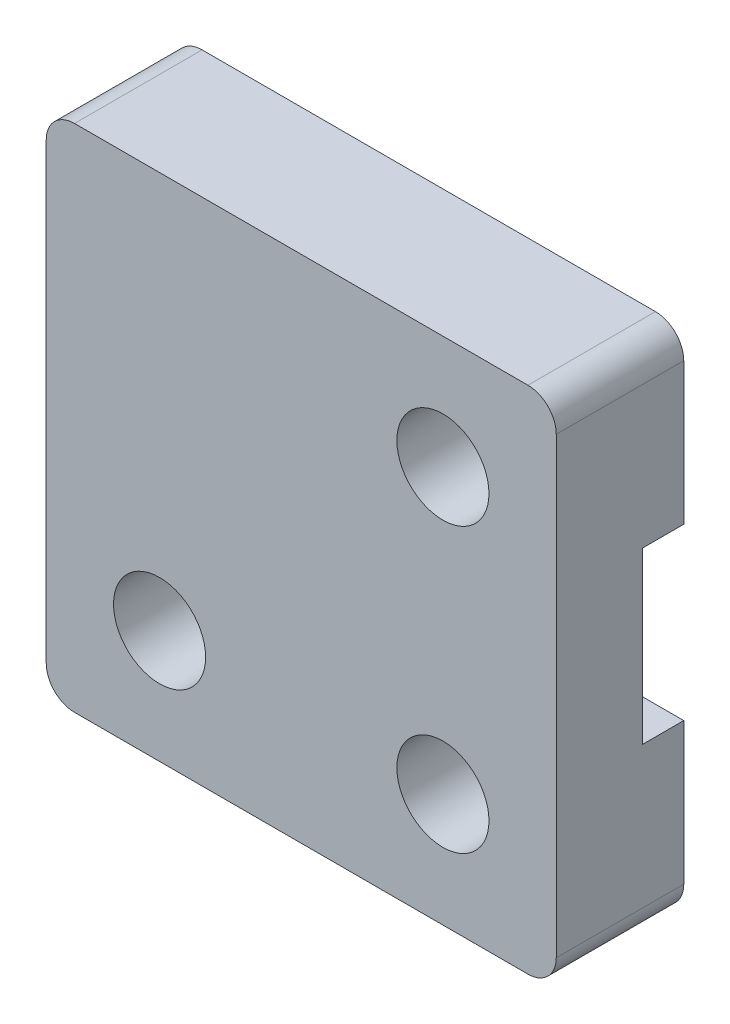
from build123d import *

# Parameters (mm, degrees)
SKETCH1_W           = 18
SKETCH1_H           = 18
SKETCH1_R           = 1.625
BOSS_EXTRUDE1_DEPTH = 4
SKETCH2_W           = 1
SKETCH2_H           = 6
CUT_EXTRUDE1_DEPTH  = 0.95
SKETCH3_R           = 1.625
BOSS_EXTRUDE2_DEPTH = 0.5
FILLET1_R           = 1


with BuildPart() as part:
    # Sketch1 → Boss-Extrude1 (new body)
    with BuildSketch(Plane.XY):
        with Locations((9, 9)):
            Rectangle(SKETCH1_W, SKETCH1_H)
        with Locations((4, 4)):
            Circle(SKETCH1_R, mode=Mode.SUBTRACT)
        with Locations((14, 4)):
            Circle(SKETCH1_R, mode=Mode.SUBTRACT)
        with Locations((14, 14)):
            Circle(SKETCH1_R, mode=Mode.SUBTRACT)
    extrude(amount=BOSS_EXTRUDE1_DEPTH)

    # Sketch2 → Cut-Extrude1 (cut)
    with BuildSketch(Plane(origin=(0, 0, 0), x_dir=(-1, 0, 0), z_dir=(0, 0, -1))):
        with Locations((-17.5, 9)):
            Rectangle(SKETCH2_W, SKETCH2_H)
        with Locations((-15.5, 9)):
            Rectangle(SKETCH2_W, SKETCH2_H)
        with Locations((-13.5, 9)):
            Rectangle(SKETCH2_W, SKETCH2_H)
        with Locations((-11.5, 9)):
            Rectangle(SKETCH2_W, SKETCH2_H)
        with Locations((-9.5, 9)):
            Rectangle(SKETCH2_W, SKETCH2_H)
        with Locations((-7.5, 9)):
            Rectangle(SKETCH2_W, SKETCH2_H)
        with Locations((-5.5, 9)):
            Rectangle(SKETCH2_W, SKETCH2_H)
        with Locations((-3.5, 9)):
            Rectangle(SKETCH2_W, SKETCH2_H)
        with Locations((-1.5, 9)):
            Rectangle(SKETCH2_W, SKETCH2_H)
    extrude(amount=-CUT_EXTRUDE1_DEPTH, mode=Mode.SUBTRACT)

    # Sketch3 → Boss-Extrude2 (add)
    with BuildSketch(Plane(origin=(0, 0, 0), x_dir=(-1, 0, 0), z_dir=(0, 0, -1))):
        Polygon((0, 0), (0, 6), (-1, 6), (-2, 6), (-3, 6), (-4, 6), (-5, 6), (-6, 6), (-7, 6), (-8, 6), (-9, 6), (-10, 6), (-11, 6), (-12, 6), (-13, 6), (-14, 6), (-15, 6), (-16, 6), (-17, 6), (-18, 6), (-18, 0), align=None)
        with Locations((-14, 4)):
            Circle(SKETCH3_R, mode=Mode.SUBTRACT)
        with Locations((-4, 4)):
            Circle(SKETCH3_R, mode=Mode.SUBTRACT)
        Polygon((0, 18), (-18, 18), (-18, 12), (-17, 12), (-16, 12), (-15, 12), (-14, 12), (-13, 12), (-12, 12), (-11, 12), (-10, 12), (-9, 12), (-8, 12), (-7, 12), (-6, 12), (-5, 12), (-4, 12), (-3, 12), (-2, 12), (-1, 12), (0, 12), align=None)
        with Locations((-14, 14)):
            Circle(SKETCH3_R, mode=Mode.SUBTRACT)
    extrude(amount=BOSS_EXTRUDE2_DEPTH)

    # Fillet1
    fillet1_edges = [part.edges().sort_by_distance(p)[0] for p in [
        (0, 18, 1.75),
        (18, 18, 1.75),
        (18, 0, 1.75),
        (0, 0, 1.75),
    ]]
    fillet(fillet1_edges, radius=FILLET1_R)


solid = part.part
